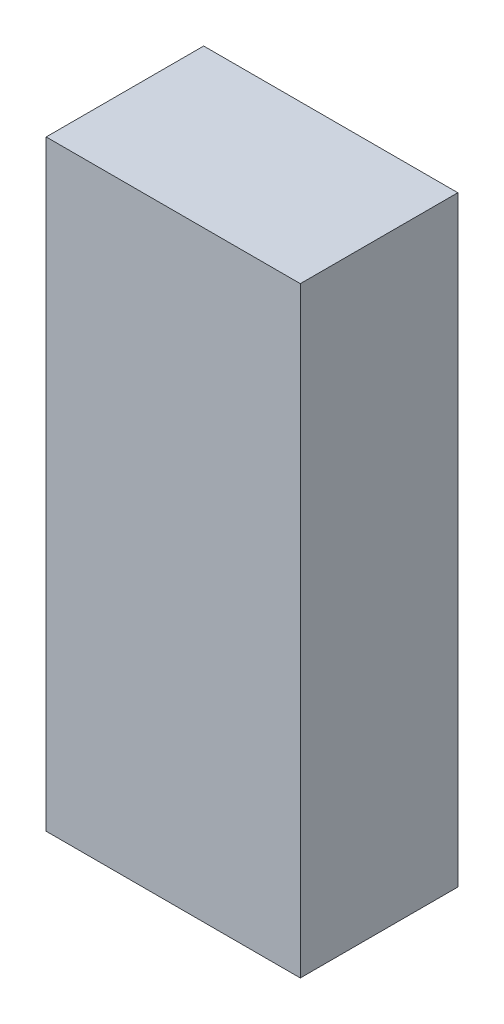
from build123d import *

# Parameters (mm, degrees)
SKETCH1_W           = 901.7
SKETCH1_H           = 558.8
BOSS_EXTRUDE1_DEPTH = 2133.6
SHELL1_T            = -3.175


with BuildPart() as part:
    # Sketch1 → Boss-Extrude1 (new body)
    with BuildSketch(Plane(origin=(0, 0, 0), x_dir=(1, 0, 0), z_dir=(0, 1, 0))):
        Rectangle(SKETCH1_W, SKETCH1_H)
    extrude(amount=BOSS_EXTRUDE1_DEPTH)

    # Shell1
    shell1_openings = [part.faces().sort_by_distance(p)[0] for p in [
        (0, 1066.8, -279.4),
    ]]
    offset(amount=SHELL1_T, openings=shell1_openings, kind=Kind.INTERSECTION)


solid = part.part
